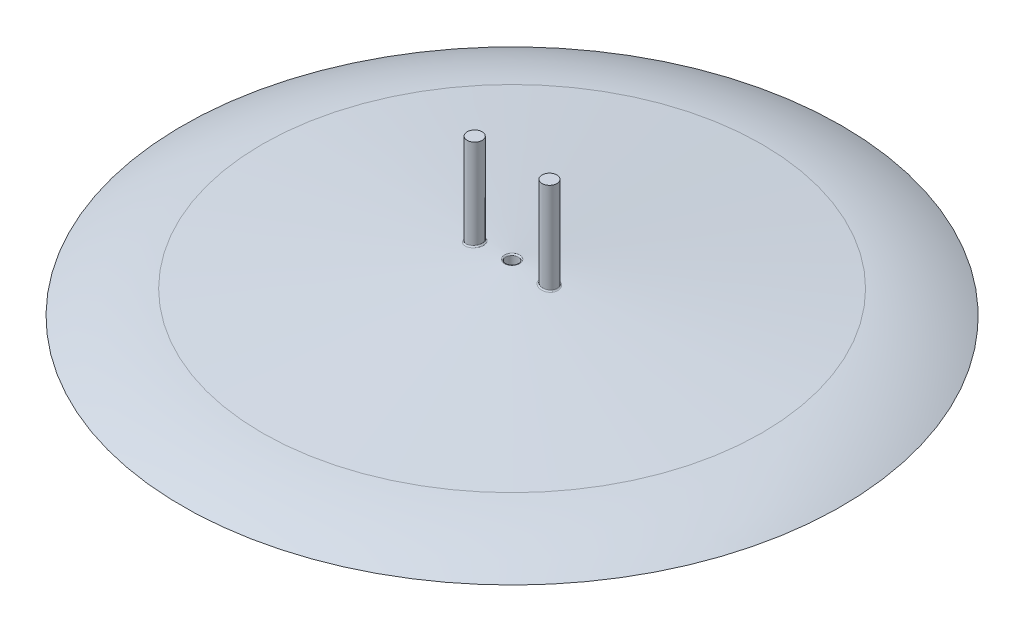
from build123d import *

# Parameters (mm, degrees)
SHELL1_T            = -10
SKETCH2_R           = 5
CUT_EXTRUDE1_DEPTH  = 377.086641577
BOSS_EXTRUDE1_REACH = 391.796
SKETCH3_R           = 6
FILLET1_R           = 1
FILLET2_R           = 1
FILLET3_R           = 1
FILLET4_R           = 1


with BuildPart() as part:
    # Sketch1 → Revolve2 (revolve)
    with BuildSketch(Plane.XY, mode=Mode.PRIVATE) as revolve2_sk:
        with BuildLine():
            Line((-5.77e-07, 0), (-5.77e-07, 39.99999759))
            Line((-5.77e-07, 39.99999759), (200.537366432, 19.016412431))
            ThreePointArc((200.537366432, 19.016412431), (233.36342878, 12.472202789), (264.425, 0))
            Line((264.425, 0), (-5.77e-07, 0))
        make_face()
    revolve(revolve2_sk.sketch.rotate(Axis((-5.77e-07, 0, 0), (0, 1, 0)), 90), axis=Axis((-5.77e-07, 0, 0), (0, 1, 0)))

    # Shell1
    shell1_openings = [part.faces().sort_by_distance(p)[0] for p in [
        (-5.77e-07, 0, 0),
    ]]
    offset(amount=SHELL1_T, openings=shell1_openings, kind=Kind.INTERSECTION)

    # Sketch2 → Cut-Extrude1 (cut, through all)
    with BuildSketch(Plane(origin=(0, 0, 0), x_dir=(1, 0, 0), z_dir=(0, 1, 0))):
        with Locations(Location((-5.77e-07, 0, 0), (0, 0, 90))):
            Circle(SKETCH2_R)
    extrude(amount=CUT_EXTRUDE1_DEPTH, mode=Mode.SUBTRACT)

    # Boss-Extrude1: up to this cone (the profile starts outside it)
    boss_extrude1_end = Plane(origin=(-5.77e-07, 110, 0), z_dir=(0, -1, 0)).offset(70.00000341) * Cone(9.557e-06, 3080.140512896, 322.29599659, align=(Align.CENTER, Align.CENTER, Align.MIN), mode=Mode.PRIVATE)
    # Sketch3 → Boss-Extrude1 (add, up to the surface)
    with BuildSketch(Plane(origin=(0, 110, 0), x_dir=(1, 0, 0), z_dir=(0, 1, 0)), mode=Mode.PRIVATE) as boss_extrude1_sk1:
        with Locations(Location((30, 0, 0), (0, 0, 270))):
            Circle(SKETCH3_R)
    boss_extrude1_tool1 = extrude(boss_extrude1_sk1.sketch, amount=-BOSS_EXTRUDE1_REACH, mode=Mode.PRIVATE) - boss_extrude1_end
    add(boss_extrude1_tool1.solids().sort_by_distance((30, 110, 0))[0])
    # Sketch3 → Boss-Extrude1 (add, up to the surface)
    with BuildSketch(Plane(origin=(0, 110, 0), x_dir=(1, 0, 0), z_dir=(0, 1, 0)), mode=Mode.PRIVATE) as boss_extrude1_sk2:
        with Locations(Location((-30, 0, 0), (0, 0, 270))):
            Circle(SKETCH3_R)
    boss_extrude1_tool2 = extrude(boss_extrude1_sk2.sketch, amount=-BOSS_EXTRUDE1_REACH, mode=Mode.PRIVATE) - boss_extrude1_end
    add(boss_extrude1_tool2.solids().sort_by_distance((-30, 110, 0))[0])

    # Fillet1
    fillet1_edges = [part.edges().sort_by_distance(p)[0] for p in [
        (-29.991450279, 36.799604991, -5.99999391),
    ]]
    fillet(fillet1_edges, radius=FILLET1_R)

    # Fillet2
    fillet2_edges = [part.edges().sort_by_distance(p)[0] for p in [
        (29.991450279, 36.799604872, -5.99999391),
    ]]
    fillet(fillet2_edges, radius=FILLET2_R)

    # Fillet3
    fillet3_edges = [part.edges().sort_by_distance(p)[0] for p in [
        (-5.77e-07, 39.47681367, 5),
    ]]
    fillet(fillet3_edges, radius=FILLET3_R)

    # Fillet4
    fillet4_edges = [part.edges().sort_by_distance(p)[0] for p in [
        (-5.77e-07, 29.422218419, 5),
    ]]
    fillet(fillet4_edges, radius=FILLET4_R)


solid = part.part
